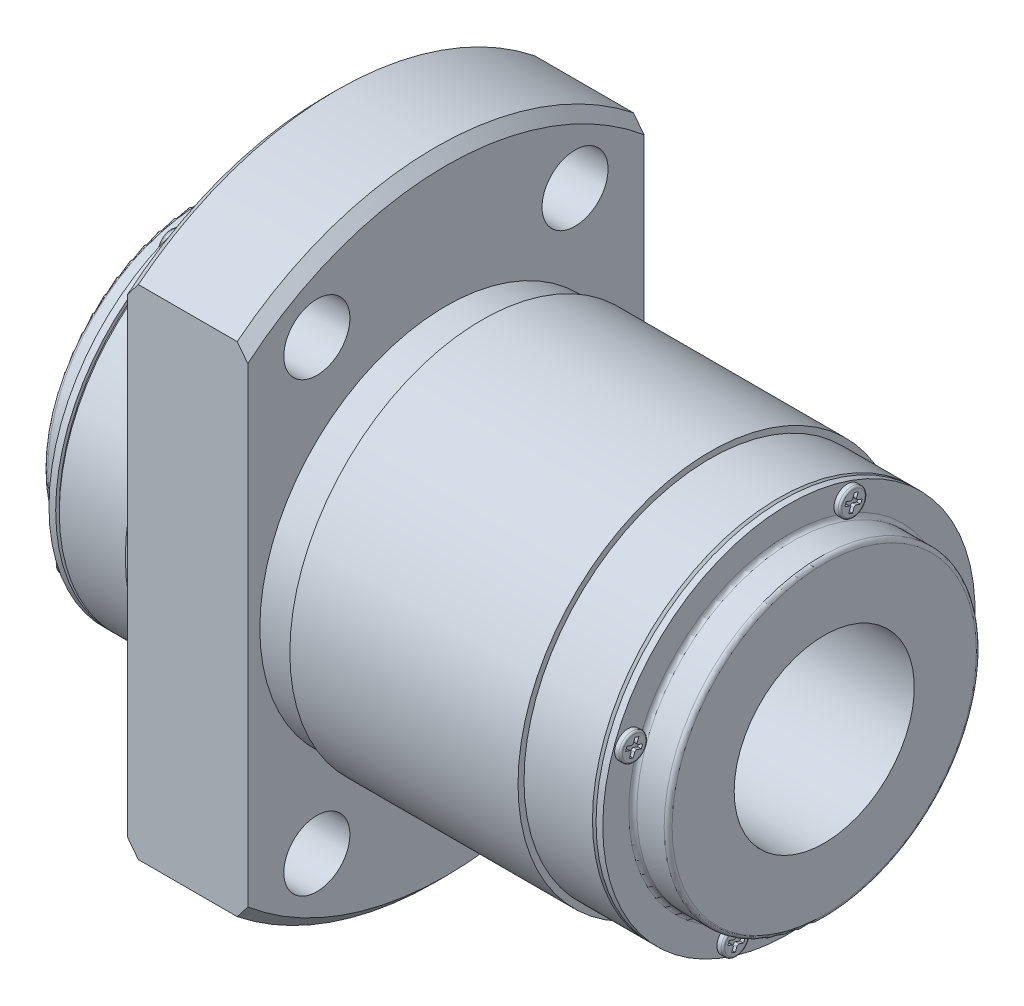
from build123d import *

# Parameters (mm, degrees)
SKETCH2_W          = 10
SKETCH2_H          = 2.75
SKETCH3_W          = 10
SKETCH3_H          = 2.75
SKETCH4_W          = 10
SKETCH4_H          = 2.75
SKETCH5_W          = 10
SKETCH5_H          = 2.75
SKETCH7_W          = 66
SKETCH7_H          = 106
SKETCH7_W_2        = 33
SKETCH7_H_2        = 55
CUT_EXTRUDE1_DEPTH = 10
CUT_EXTRUDE2_DEPTH = 0.3
CUT_EXTRUDE3_DEPTH = 0.3
CUT_EXTRUDE4_DEPTH = 0.3
CUT_EXTRUDE5_DEPTH = 0.3
CUT_EXTRUDE6_DEPTH = 0.3
CUT_EXTRUDE7_DEPTH = 0.3
CUT_EXTRUDE8_DEPTH = 0.3
CUT_EXTRUDE9_DEPTH = 0.3


with BuildPart() as part:
    # Sketch1 → Revolve1 (revolve)
    with BuildSketch(Plane.XY):
        with BuildLine():
            Line((-3.5, 7.5), (48.5, 7.5))
            Line((48.5, 7.5), (48.5, 12.67))
            ThreePointArc((48.5, 12.67), (48.403345238, 12.903345238), (48.17, 13))
            Line((48.17, 13), (45.89, 13))
            ThreePointArc((45.89, 13), (45.656654762, 13.096654762), (45.56, 13.33))
            Line((45.56, 13.33), (45.56, 15.5))
            Line((45.56, 15.5), (45, 15.5))
            Line((45, 15.5), (45, 15.2))
            Line((45, 15.2), (44.7, 15.5))
            Line((44.7, 15.5), (39, 15.5))
            Line((39, 15.5), (39, 16))
            Line((39, 16), (20, 16))
            Line((20, 16), (20, 15.5))
            Line((20, 15.5), (17, 15.5))
            Line((17, 15.5), (17, 25.616666667))
            Line((17, 25.616666667), (16.116666667, 26.5))
            Line((16.116666667, 26.5), (7.883333333, 26.5))
            Line((7.883333333, 26.5), (7, 25.616666667))
            Line((7, 25.616666667), (7, 16))
            Line((7, 16), (6.3, 16))
            Line((6.3, 16), (6.3, 15.5))
            Line((6.3, 15.5), (0.3, 15.5))
            Line((0.3, 15.5), (0, 15.2))
            Line((0, 15.2), (0, 15.5))
            Line((0, 15.5), (-0.56, 15.5))
            Line((-0.56, 15.5), (-0.56, 13.33))
            ThreePointArc((-0.56, 13.33), (-0.656654762, 13.096654762), (-0.89, 13))
            Line((-0.89, 13), (-3.17, 13))
            ThreePointArc((-3.17, 13), (-3.403345238, 12.903345238), (-3.5, 12.67))
            Line((-3.5, 12.67), (-3.5, 7.5))
        make_face()
    revolve(axis=Axis((45, 0, 0), (-1, 0, 0)))

    # Sketch2 → Cut-Revolve1 (revolve, cut)
    with BuildSketch(Plane(origin=(0, 0, 0), x_dir=(1, 0, 0), z_dir=(0, -0.5, 0.866025404))):
        with Locations((12, 22.875)):
            Rectangle(SKETCH2_W, SKETCH2_H)
    revolve(axis=Axis((17, 18.619546181, 10.75), (-1, 0, 0)), mode=Mode.SUBTRACT)

    # Sketch3 → Cut-Revolve2 (revolve, cut)
    with BuildSketch(Plane(origin=(0, 0, 0), x_dir=(1, 0, 0), z_dir=(0, -0.5, 0.866025404))):
        with Locations((12, -20.125)):
            Rectangle(SKETCH3_W, SKETCH3_H)
    revolve(axis=Axis((17, -18.619546181, -10.75), (-1, 0, 0)), mode=Mode.SUBTRACT)

    # Sketch4 → Cut-Revolve3 (revolve, cut)
    with BuildSketch(Plane(origin=(0, 0, 0), x_dir=(1, 0, 0), z_dir=(0, 0.5, 0.866025404))):
        with Locations((12, 22.875)):
            Rectangle(SKETCH4_W, SKETCH4_H)
    revolve(axis=Axis((17, 18.619546181, -10.75), (-1, 0, 0)), mode=Mode.SUBTRACT)

    # Sketch5 → Cut-Revolve4 (revolve, cut)
    with BuildSketch(Plane(origin=(0, 0, 0), x_dir=(1, 0, 0), z_dir=(0, 0.5, 0.866025404))):
        with Locations((12, -20.125)):
            Rectangle(SKETCH5_W, SKETCH5_H)
    revolve(axis=Axis((17, -18.619546181, 10.75), (-1, 0, 0)), mode=Mode.SUBTRACT)

    # Sketch6 → Cut-Revolve5 (revolve, cut)
    with BuildSketch(Plane.XY):
        Polygon((12, -5.5), (14.4585, -6.919415637), (14.4585, -25.9585), (15, -26.5), (12, -26.5), align=None)
    revolve(axis=Axis((12, -26.5, 0), (0, 1, 0)), mode=Mode.SUBTRACT)

    # Sketch7 → Cut-Extrude1 (cut)
    with BuildSketch(Plane(origin=(17, 0, 0), x_dir=(0, 0, -1), z_dir=(1, 0, 0))):
        Rectangle(SKETCH7_W, SKETCH7_H)
        Rectangle(SKETCH7_W_2, SKETCH7_H_2, mode=Mode.SUBTRACT)
    extrude(amount=-CUT_EXTRUDE1_DEPTH, mode=Mode.SUBTRACT)

    # Sketch8 → Revolve2 (revolve)
    with BuildSketch(Plane(origin=(0, 0, 0), x_dir=(1, 0, 0), z_dir=(0, -0.342020143, 0.939692621))):
        with BuildLine():
            Line((-1.06, 14.25), (-1.06, 15.17))
            ThreePointArc((-1.06, 15.17), (-1.001421356, 15.311421356), (-0.86, 15.37))
            Line((-0.86, 15.37), (-0.56, 15.37))
            Line((-0.56, 15.37), (-0.56, 14.25))
            Line((-0.56, 14.25), (-1.06, 14.25))
        make_face()
    revolve(axis=Axis((-0.56, 13.390619846, 4.873787042), (-1, 0, 0)))

    # Sketch9 → Revolve3 (revolve)
    with BuildSketch(Plane(origin=(0, -4.873787042, 13.390619846), x_dir=(1, 0, 0), z_dir=(0, -0.342020143, 0.939692621))):
        with BuildLine():
            Line((-1.06, 0), (-1.06, 0.92))
            ThreePointArc((-1.06, 0.92), (-1.001421356, 1.061421356), (-0.86, 1.12))
            Line((-0.86, 1.12), (-0.56, 1.12))
            Line((-0.56, 1.12), (-0.56, 0))
            Line((-0.56, 0), (-1.06, 0))
        make_face()
    revolve(axis=Axis((-0.56, -4.873787042, 13.390619846), (-1, 0, 0)))

    # Sketch10 → Revolve4 (revolve)
    with BuildSketch(Plane(origin=(0, 0, 0), x_dir=(1, 0, 0), z_dir=(0, -0.342020143, 0.939692621))):
        with BuildLine():
            Line((-1.06, -14.25), (-1.06, -13.33))
            ThreePointArc((-1.06, -13.33), (-1.001421356, -13.188578644), (-0.86, -13.13))
            Line((-0.86, -13.13), (-0.56, -13.13))
            Line((-0.56, -13.13), (-0.56, -14.25))
            Line((-0.56, -14.25), (-1.06, -14.25))
        make_face()
    revolve(axis=Axis((-0.56, -13.390619846, -4.873787042), (-1, 0, 0)))

    # Sketch11 → Revolve5 (revolve)
    with BuildSketch(Plane(origin=(0, 4.873787042, -13.390619846), x_dir=(1, 0, 0), z_dir=(0, -0.342020143, 0.939692621))):
        with BuildLine():
            Line((-1.06, 0), (-1.06, 0.92))
            ThreePointArc((-1.06, 0.92), (-1.001421356, 1.061421356), (-0.86, 1.12))
            Line((-0.86, 1.12), (-0.56, 1.12))
            Line((-0.56, 1.12), (-0.56, 0))
            Line((-0.56, 0), (-1.06, 0))
        make_face()
    revolve(axis=Axis((-0.56, 4.873787042, -13.390619846), (-1, 0, 0)))

    # Sketch12 → Revolve6 (revolve)
    with BuildSketch(Plane(origin=(0, 0, 0), x_dir=(1, 0, 0), z_dir=(0, 0.342020143, 0.939692621))):
        with BuildLine():
            Line((45.56, 14.25), (45.56, 15.37))
            Line((45.56, 15.37), (45.91, 15.37))
            ThreePointArc((45.91, 15.37), (46.016066017, 15.326066017), (46.06, 15.22))
            Line((46.06, 15.22), (46.06, 14.25))
            Line((46.06, 14.25), (45.56, 14.25))
        make_face()
    revolve(axis=Axis((46.06, 13.390619846, -4.873787042), (-1, 0, 0)))

    # Sketch13 → Revolve7 (revolve)
    with BuildSketch(Plane(origin=(0, -4.873787042, -13.390619846), x_dir=(1, 0, 0), z_dir=(0, 0.342020143, 0.939692621))):
        with BuildLine():
            Line((45.56, 0), (45.56, 1.12))
            Line((45.56, 1.12), (45.91, 1.12))
            ThreePointArc((45.91, 1.12), (46.016066017, 1.076066017), (46.06, 0.97))
            Line((46.06, 0.97), (46.06, 0))
            Line((46.06, 0), (45.56, 0))
        make_face()
    revolve(axis=Axis((46.06, -4.873787042, -13.390619846), (-1, 0, 0)))

    # Sketch14 → Revolve8 (revolve)
    with BuildSketch(Plane(origin=(0, 0, 0), x_dir=(1, 0, 0), z_dir=(0, 0.342020143, 0.939692621))):
        with BuildLine():
            Line((45.56, -14.25), (45.56, -13.13))
            Line((45.56, -13.13), (45.91, -13.13))
            ThreePointArc((45.91, -13.13), (46.016066017, -13.173933983), (46.06, -13.28))
            Line((46.06, -13.28), (46.06, -14.25))
            Line((46.06, -14.25), (45.56, -14.25))
        make_face()
    revolve(axis=Axis((46.06, -13.390619846, 4.873787042), (-1, 0, 0)))

    # Sketch15 → Revolve9 (revolve)
    with BuildSketch(Plane(origin=(0, 4.873787042, 13.390619846), x_dir=(1, 0, 0), z_dir=(0, 0.342020143, 0.939692621))):
        with BuildLine():
            Line((45.56, 0), (45.56, 1.12))
            Line((45.56, 1.12), (45.91, 1.12))
            ThreePointArc((45.91, 1.12), (46.016066017, 1.076066017), (46.06, 0.97))
            Line((46.06, 0.97), (46.06, 0))
            Line((46.06, 0), (45.56, 0))
        make_face()
    revolve(axis=Axis((46.06, 4.873787042, 13.390619846), (-1, 0, 0)))

    # Sketch16 → Cut-Extrude2 (cut)
    with BuildSketch(Plane(origin=(46.06, 0, 0), x_dir=(0, 0, -1), z_dir=(1, 0, 0))):
        with BuildLine():
            Line((4.164267347, 13.473274563), (4.511953617, 13.34672711))
            ThreePointArc((4.511953617, 13.34672711), (4.60223964, 13.263995213), (4.607581213, 13.141653068))
            Line((4.607581213, 13.141653068), (4.48103376, 12.793966798))
            Line((4.48103376, 12.793966798), (4.791132325, 12.681100151))
            Line((4.791132325, 12.681100151), (4.917679778, 13.028786421))
            ThreePointArc((4.917679778, 13.028786421), (5.000411676, 13.119072444), (5.12275382, 13.124414017))
            Line((5.12275382, 13.124414017), (5.47044009, 12.997866564))
            Line((5.47044009, 12.997866564), (5.583306737, 13.307965129))
            Line((5.583306737, 13.307965129), (5.235620468, 13.434512582))
            ThreePointArc((5.235620468, 13.434512582), (5.145334445, 13.517244479), (5.139992871, 13.639586624))
            Line((5.139992871, 13.639586624), (5.266540324, 13.987272894))
            Line((5.266540324, 13.987272894), (4.95644176, 14.100139541))
            Line((4.95644176, 14.100139541), (4.829894307, 13.752453272))
            ThreePointArc((4.829894307, 13.752453272), (4.747162409, 13.662167249), (4.624820264, 13.656825675))
            Line((4.624820264, 13.656825675), (4.277133995, 13.783373128))
            Line((4.277133995, 13.783373128), (4.164267347, 13.473274563))
        make_face()
    extrude(amount=-CUT_EXTRUDE2_DEPTH, mode=Mode.SUBTRACT)

    # Sketch17 → Cut-Extrude3 (cut)
    with BuildSketch(Plane(origin=(46.06, 0, 0), x_dir=(0, 0, -1), z_dir=(1, 0, 0))):
        with BuildLine():
            Line((-14.100139541, 4.95644176), (-13.752453272, 4.829894307))
            ThreePointArc((-13.752453272, 4.829894307), (-13.662167249, 4.747162409), (-13.656825675, 4.624820264))
            Line((-13.656825675, 4.624820264), (-13.783373128, 4.277133995))
            Line((-13.783373128, 4.277133995), (-13.473274563, 4.164267347))
            Line((-13.473274563, 4.164267347), (-13.34672711, 4.511953617))
            ThreePointArc((-13.34672711, 4.511953617), (-13.263995213, 4.60223964), (-13.141653068, 4.607581213))
            Line((-13.141653068, 4.607581213), (-12.793966798, 4.48103376))
            Line((-12.793966798, 4.48103376), (-12.681100151, 4.791132325))
            Line((-12.681100151, 4.791132325), (-13.028786421, 4.917679778))
            ThreePointArc((-13.028786421, 4.917679778), (-13.119072444, 5.000411676), (-13.124414017, 5.12275382))
            Line((-13.124414017, 5.12275382), (-12.997866564, 5.47044009))
            Line((-12.997866564, 5.47044009), (-13.307965129, 5.583306737))
            Line((-13.307965129, 5.583306737), (-13.434512582, 5.235620468))
            ThreePointArc((-13.434512582, 5.235620468), (-13.517244479, 5.145334445), (-13.639586624, 5.139992871))
            Line((-13.639586624, 5.139992871), (-13.987272894, 5.266540324))
            Line((-13.987272894, 5.266540324), (-14.100139541, 4.95644176))
        make_face()
    extrude(amount=-CUT_EXTRUDE3_DEPTH, mode=Mode.SUBTRACT)

    # Sketch18 → Cut-Extrude4 (cut)
    with BuildSketch(Plane(origin=(46.06, 0, 0), x_dir=(0, 0, -1), z_dir=(1, 0, 0))):
        with BuildLine():
            Line((-5.583306737, -13.307965129), (-5.235620468, -13.434512582))
            ThreePointArc((-5.235620468, -13.434512582), (-5.145334445, -13.517244479), (-5.139992871, -13.639586624))
            Line((-5.139992871, -13.639586624), (-5.266540324, -13.987272894))
            Line((-5.266540324, -13.987272894), (-4.95644176, -14.100139541))
            Line((-4.95644176, -14.100139541), (-4.829894307, -13.752453272))
            ThreePointArc((-4.829894307, -13.752453272), (-4.747162409, -13.662167249), (-4.624820264, -13.656825675))
            Line((-4.624820264, -13.656825675), (-4.277133995, -13.783373128))
            Line((-4.277133995, -13.783373128), (-4.164267347, -13.473274563))
            Line((-4.164267347, -13.473274563), (-4.511953617, -13.34672711))
            ThreePointArc((-4.511953617, -13.34672711), (-4.60223964, -13.263995213), (-4.607581213, -13.141653068))
            Line((-4.607581213, -13.141653068), (-4.48103376, -12.793966798))
            Line((-4.48103376, -12.793966798), (-4.791132325, -12.681100151))
            Line((-4.791132325, -12.681100151), (-4.917679778, -13.028786421))
            ThreePointArc((-4.917679778, -13.028786421), (-5.000411676, -13.119072444), (-5.12275382, -13.124414017))
            Line((-5.12275382, -13.124414017), (-5.47044009, -12.997866564))
            Line((-5.47044009, -12.997866564), (-5.583306737, -13.307965129))
        make_face()
    extrude(amount=-CUT_EXTRUDE4_DEPTH, mode=Mode.SUBTRACT)

    # Sketch19 → Cut-Extrude5 (cut)
    with BuildSketch(Plane(origin=(46.06, 0, 0), x_dir=(0, 0, -1), z_dir=(1, 0, 0))):
        with BuildLine():
            Line((12.681100151, -4.791132325), (13.028786421, -4.917679778))
            ThreePointArc((13.028786421, -4.917679778), (13.119072444, -5.000411676), (13.124414017, -5.12275382))
            Line((13.124414017, -5.12275382), (12.997866564, -5.47044009))
            Line((12.997866564, -5.47044009), (13.307965129, -5.583306737))
            Line((13.307965129, -5.583306737), (13.434512582, -5.235620468))
            ThreePointArc((13.434512582, -5.235620468), (13.517244479, -5.145334445), (13.639586624, -5.139992871))
            Line((13.639586624, -5.139992871), (13.987272894, -5.266540324))
            Line((13.987272894, -5.266540324), (14.100139541, -4.95644176))
            Line((14.100139541, -4.95644176), (13.752453272, -4.829894307))
            ThreePointArc((13.752453272, -4.829894307), (13.662167249, -4.747162409), (13.656825675, -4.624820264))
            Line((13.656825675, -4.624820264), (13.783373128, -4.277133995))
            Line((13.783373128, -4.277133995), (13.473274563, -4.164267347))
            Line((13.473274563, -4.164267347), (13.34672711, -4.511953617))
            ThreePointArc((13.34672711, -4.511953617), (13.263995213, -4.60223964), (13.141653068, -4.607581213))
            Line((13.141653068, -4.607581213), (12.793966798, -4.48103376))
            Line((12.793966798, -4.48103376), (12.681100151, -4.791132325))
        make_face()
    extrude(amount=-CUT_EXTRUDE5_DEPTH, mode=Mode.SUBTRACT)

    # Sketch20 → Cut-Extrude6 (cut)
    with BuildSketch(Plane(origin=(-1.06, 0, 0), x_dir=(0, 0, -1), z_dir=(1, 0, 0))):
        with BuildLine():
            Line((-5.583306737, 13.307965129), (-5.47044009, 12.997866564))
            Line((-5.47044009, 12.997866564), (-5.12275382, 13.124414017))
            ThreePointArc((-5.12275382, 13.124414017), (-5.000411676, 13.119072444), (-4.917679778, 13.028786421))
            Line((-4.917679778, 13.028786421), (-4.791132325, 12.681100151))
            Line((-4.791132325, 12.681100151), (-4.48103376, 12.793966798))
            Line((-4.48103376, 12.793966798), (-4.607581213, 13.141653068))
            ThreePointArc((-4.607581213, 13.141653068), (-4.60223964, 13.263995213), (-4.511953617, 13.34672711))
            Line((-4.511953617, 13.34672711), (-4.164267347, 13.473274563))
            Line((-4.164267347, 13.473274563), (-4.277133995, 13.783373128))
            Line((-4.277133995, 13.783373128), (-4.624820264, 13.656825675))
            ThreePointArc((-4.624820264, 13.656825675), (-4.747162409, 13.662167249), (-4.829894307, 13.752453272))
            Line((-4.829894307, 13.752453272), (-4.95644176, 14.100139541))
            Line((-4.95644176, 14.100139541), (-5.266540324, 13.987272894))
            Line((-5.266540324, 13.987272894), (-5.139992871, 13.639586624))
            ThreePointArc((-5.139992871, 13.639586624), (-5.145334445, 13.517244479), (-5.235620468, 13.434512582))
            Line((-5.235620468, 13.434512582), (-5.583306737, 13.307965129))
        make_face()
    extrude(amount=CUT_EXTRUDE6_DEPTH, mode=Mode.SUBTRACT)

    # Sketch21 → Cut-Extrude7 (cut)
    with BuildSketch(Plane(origin=(-1.06, 0, 0), x_dir=(0, 0, -1), z_dir=(1, 0, 0))):
        with BuildLine():
            Line((-14.100139541, -4.95644176), (-13.987272894, -5.266540324))
            Line((-13.987272894, -5.266540324), (-13.639586624, -5.139992871))
            ThreePointArc((-13.639586624, -5.139992871), (-13.517244479, -5.145334445), (-13.434512582, -5.235620468))
            Line((-13.434512582, -5.235620468), (-13.307965129, -5.583306737))
            Line((-13.307965129, -5.583306737), (-12.997866564, -5.47044009))
            Line((-12.997866564, -5.47044009), (-13.124414017, -5.12275382))
            ThreePointArc((-13.124414017, -5.12275382), (-13.119072444, -5.000411676), (-13.028786421, -4.917679778))
            Line((-13.028786421, -4.917679778), (-12.681100151, -4.791132325))
            Line((-12.681100151, -4.791132325), (-12.793966798, -4.48103376))
            Line((-12.793966798, -4.48103376), (-13.141653068, -4.607581213))
            ThreePointArc((-13.141653068, -4.607581213), (-13.263995213, -4.60223964), (-13.34672711, -4.511953617))
            Line((-13.34672711, -4.511953617), (-13.473274563, -4.164267347))
            Line((-13.473274563, -4.164267347), (-13.783373128, -4.277133995))
            Line((-13.783373128, -4.277133995), (-13.656825675, -4.624820264))
            ThreePointArc((-13.656825675, -4.624820264), (-13.662167249, -4.747162409), (-13.752453272, -4.829894307))
            Line((-13.752453272, -4.829894307), (-14.100139541, -4.95644176))
        make_face()
    extrude(amount=CUT_EXTRUDE7_DEPTH, mode=Mode.SUBTRACT)

    # Sketch22 → Cut-Extrude8 (cut)
    with BuildSketch(Plane(origin=(-1.06, 0, 0), x_dir=(0, 0, -1), z_dir=(1, 0, 0))):
        with BuildLine():
            Line((4.164267347, -13.473274563), (4.277133995, -13.783373128))
            Line((4.277133995, -13.783373128), (4.624820264, -13.656825675))
            ThreePointArc((4.624820264, -13.656825675), (4.747162409, -13.662167249), (4.829894307, -13.752453272))
            Line((4.829894307, -13.752453272), (4.95644176, -14.100139541))
            Line((4.95644176, -14.100139541), (5.266540324, -13.987272894))
            Line((5.266540324, -13.987272894), (5.139992871, -13.639586624))
            ThreePointArc((5.139992871, -13.639586624), (5.145334445, -13.517244479), (5.235620468, -13.434512582))
            Line((5.235620468, -13.434512582), (5.583306737, -13.307965129))
            Line((5.583306737, -13.307965129), (5.47044009, -12.997866564))
            Line((5.47044009, -12.997866564), (5.12275382, -13.124414017))
            ThreePointArc((5.12275382, -13.124414017), (5.000411676, -13.119072444), (4.917679778, -13.028786421))
            Line((4.917679778, -13.028786421), (4.791132325, -12.681100151))
            Line((4.791132325, -12.681100151), (4.48103376, -12.793966798))
            Line((4.48103376, -12.793966798), (4.607581213, -13.141653068))
            ThreePointArc((4.607581213, -13.141653068), (4.60223964, -13.263995213), (4.511953617, -13.34672711))
            Line((4.511953617, -13.34672711), (4.164267347, -13.473274563))
        make_face()
    extrude(amount=CUT_EXTRUDE8_DEPTH, mode=Mode.SUBTRACT)

    # Sketch23 → Cut-Extrude9 (cut)
    with BuildSketch(Plane(origin=(-1.06, 0, 0), x_dir=(0, 0, -1), z_dir=(1, 0, 0))):
        with BuildLine():
            Line((12.681100151, 4.791132325), (12.793966798, 4.48103376))
            Line((12.793966798, 4.48103376), (13.141653068, 4.607581213))
            ThreePointArc((13.141653068, 4.607581213), (13.263995213, 4.60223964), (13.34672711, 4.511953617))
            Line((13.34672711, 4.511953617), (13.473274563, 4.164267347))
            Line((13.473274563, 4.164267347), (13.783373128, 4.277133995))
            Line((13.783373128, 4.277133995), (13.656825675, 4.624820264))
            ThreePointArc((13.656825675, 4.624820264), (13.662167249, 4.747162409), (13.752453272, 4.829894307))
            Line((13.752453272, 4.829894307), (14.100139541, 4.95644176))
            Line((14.100139541, 4.95644176), (13.987272894, 5.266540324))
            Line((13.987272894, 5.266540324), (13.639586624, 5.139992871))
            ThreePointArc((13.639586624, 5.139992871), (13.517244479, 5.145334445), (13.434512582, 5.235620468))
            Line((13.434512582, 5.235620468), (13.307965129, 5.583306737))
            Line((13.307965129, 5.583306737), (12.997866564, 5.47044009))
            Line((12.997866564, 5.47044009), (13.124414017, 5.12275382))
            ThreePointArc((13.124414017, 5.12275382), (13.119072444, 5.000411676), (13.028786421, 4.917679778))
            Line((13.028786421, 4.917679778), (12.681100151, 4.791132325))
        make_face()
    extrude(amount=CUT_EXTRUDE9_DEPTH, mode=Mode.SUBTRACT)


solid = part.part
